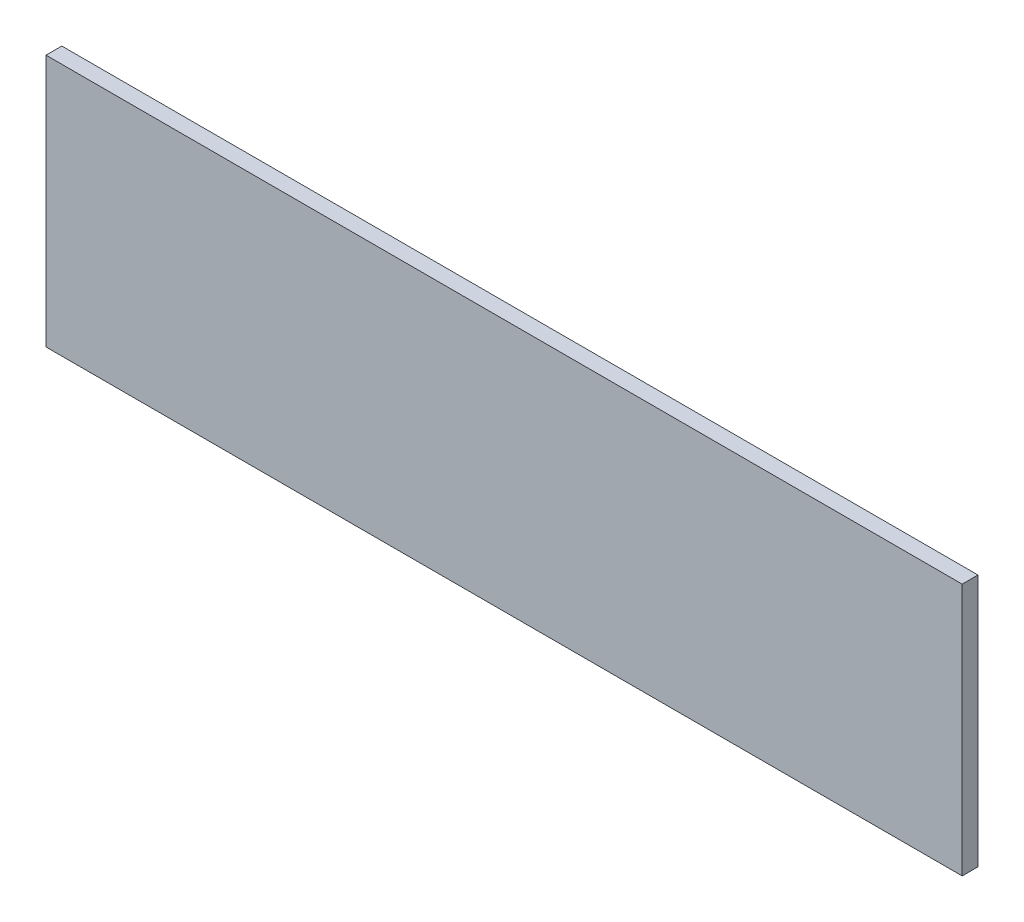
from build123d import *

# Parameters (mm, degrees)
SKETCH2_W           = 184.15
SKETCH2_H           = 50.8
BOSS_EXTRUDE1_DEPTH = 1.5875


with BuildPart() as part:
    # Sketch2 → Boss-Extrude1 (new body, symmetric)
    with BuildSketch(Plane.XY):
        Rectangle(SKETCH2_W, SKETCH2_H)
    extrude(amount=BOSS_EXTRUDE1_DEPTH, both=True)


solid = part.part
